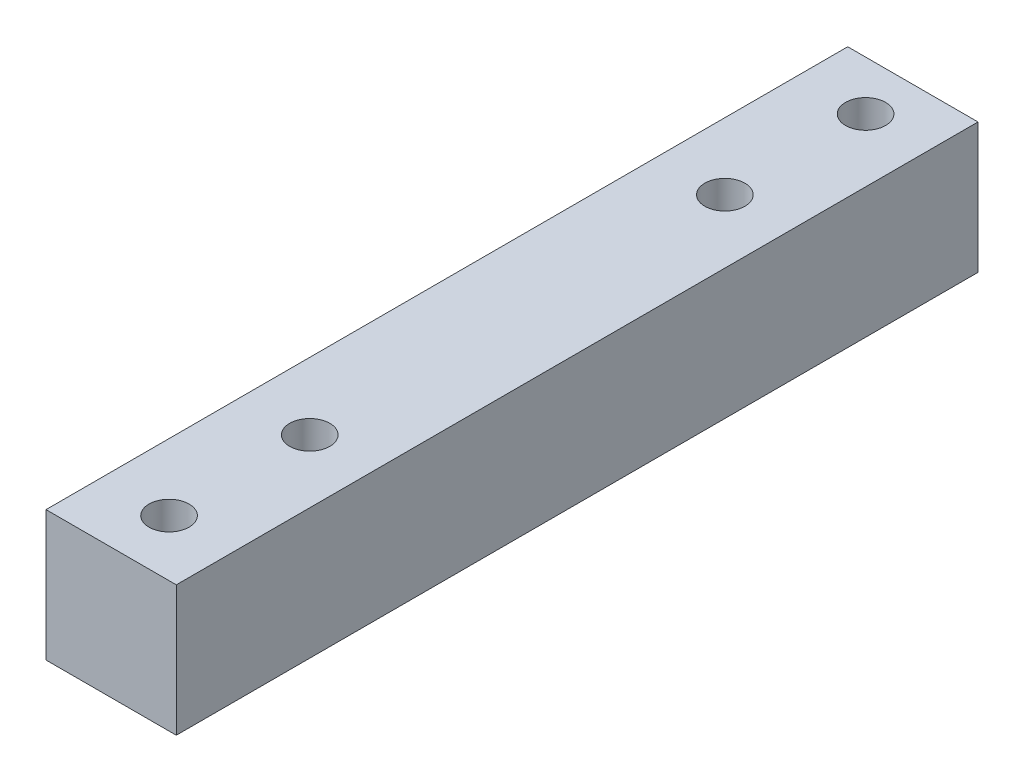
from build123d import *

# Parameters (mm, degrees)
SKETCH1_W           = 13
SKETCH1_H           = 13
BOSS_EXTRUDE1_DEPTH = 80
SKETCH2_R           = 2
CUT_EXTRUDE1_DEPTH  = 80


with BuildPart() as part:
    # Sketch1 → Boss-Extrude1 (new body)
    with BuildSketch(Plane.XY):
        with Locations((0, 0.30952381)):
            Rectangle(SKETCH1_W, SKETCH1_H)
    extrude(amount=BOSS_EXTRUDE1_DEPTH)

    # Sketch2 → Cut-Extrude1 (cut)
    with BuildSketch(Plane(origin=(0, 6.80952381, 0), x_dir=(1, 0, 0), z_dir=(0, 1, 0))):
        with Locations((0.197793721, -4.916885497)):
            Circle(SKETCH2_R)
        with Locations((0.157458731, -18.916885497)):
            Circle(SKETCH2_R)
        with Locations((0.197793721, -60.379313969)):
            Circle(SKETCH2_R)
        with Locations((0.157458731, -74.379313969)):
            Circle(SKETCH2_R)
    extrude(amount=-CUT_EXTRUDE1_DEPTH, mode=Mode.SUBTRACT)


solid = part.part
